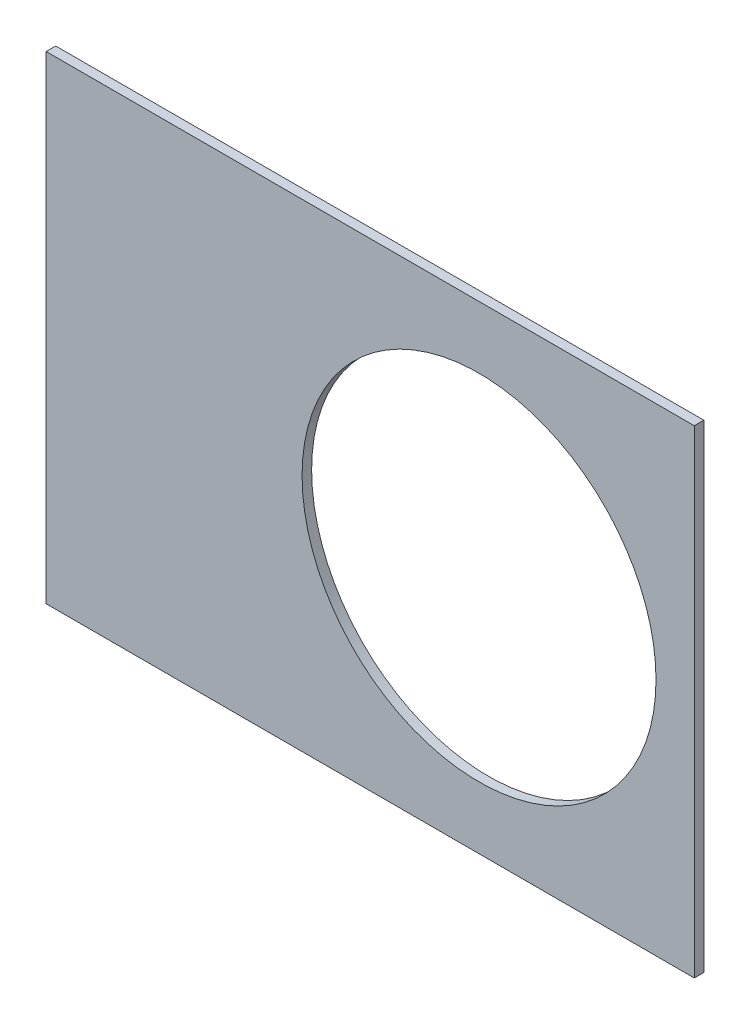
from build123d import *

# Parameters (mm, degrees)
BOSS_EXTRUDE1_DEPTH = 0.254
SKETCH2_R           = 4.699
CUT_EXTRUDE1_DEPTH  = 1.254
SKETCH3_W           = 2.54
SKETCH3_H           = 0.635
CUT_EXTRUDE2_DEPTH  = 1.254
SKETCH5_OUTSIDE_W   = 121.447
SKETCH5_OUTSIDE_H   = 109.618
SKETCH5_OUTSIDE_W_2 = 17.2085
SKETCH5_OUTSIDE_H_2 = 15.24
CUT_EXTRUDE5_DEPTH  = 1.254


with BuildPart() as part:
    # Sketch1 → Boss-Extrude1 (new body)
    with BuildSketch(Plane.XY):
        with BuildLine():
            Line((67.21146711, 76.191723231), (8.696654013, 17.676910134))
            Line((8.696654013, 17.676910134), (7.228954972, 14.133571205))
            ThreePointArc((7.228954972, 14.133571205), (14.666587579, 6.075099489), (15.105587123, -4.88230096))
            Line((15.105587123, -4.88230096), (18.648926052, -6.35))
            Line((18.648926052, -6.35), (101.401368334, -6.35))
            ThreePointArc((101.401368334, -6.35), (93.866160503, 38.880636728), (67.21146711, 76.191723231))
        make_face()
        with BuildLine():
            Line((88.672924278, 6.35), (27.86051193, 6.35))
            ThreePointArc((27.86051193, 6.35), (26.399857642, 10.93517908), (24.190484974, 15.210228852))
            Line((24.190484974, 15.210228852), (67.191354125, 58.211098004))
            ThreePointArc((67.191354125, 58.211098004), (82.13289044, 34.020557137), (88.672924278, 6.35))
        make_face(mode=Mode.SUBTRACT)
    extrude(amount=BOSS_EXTRUDE1_DEPTH)

    # Sketch2 → Cut-Extrude1 (cut, through all)
    with BuildSketch(Plane.XY.offset(0.254)):
        with Locations((22.225, 0)):
            Circle(SKETCH2_R)
        with Locations((36.195, 0)):
            Circle(SKETCH2_R)
        with Locations((61.722, 0)):
            Circle(SKETCH2_R)
        with Locations((75.692, 0)):
            Circle(SKETCH2_R)
        with Locations((95.25, 0)):
            Circle(SKETCH2_R)
        with Locations((15.715448212, 15.715448212)):
            Circle(SKETCH2_R)
        with Locations((25.593729945, 25.593729945)):
            Circle(SKETCH2_R)
        with Locations((43.644044748, 43.644044748)):
            Circle(SKETCH2_R)
        with Locations((53.522326482, 53.522326482)):
            Circle(SKETCH2_R)
        with Locations((92.004434954, 24.652514046)):
            Circle(SKETCH2_R)
        with Locations((82.48891971, 47.625)):
            Circle(SKETCH2_R)
        with Locations((67.351920908, 67.351920908)):
            Circle(SKETCH2_R)
    extrude(amount=-CUT_EXTRUDE1_DEPTH, mode=Mode.SUBTRACT)

    # Sketch3 → Cut-Extrude2 (cut, through all)
    with BuildSketch(Plane.XY.offset(0.254)):
        Polygon((15.266435406, 24.246691527), (17.06248663, 26.042742751), (17.511499436, 25.593729945), (15.715448212, 23.797678721), align=None)
        Polygon((44.991083167, 53.971339288), (43.195031942, 52.175288063), (43.644044748, 51.726275257), (45.440095973, 53.522326482), align=None)
        with Locations((29.21, -6.0325)):
            Rectangle(SKETCH3_W, SKETCH3_H)
        with Locations((68.707, -6.0325)):
            Rectangle(SKETCH3_W, SKETCH3_H)
        Polygon((29.230733674, 38.210989795), (31.026784898, 40.007041019), (31.475797704, 39.558028213), (29.67974648, 37.761976989), align=None)
        Polygon((56.845021246, 65.825277367), (55.048970022, 64.029226143), (55.497982828, 63.580213337), (57.294034052, 65.376264561), align=None)
        with Locations((48.9585, -6.0325)):
            Rectangle(SKETCH3_W, SKETCH3_H)
        with Locations((85.471, -6.0325)):
            Rectangle(SKETCH3_W, SKETCH3_H)
        Polygon((99.935462164, 14.437711971), (100.266998693, 11.919442024), (101.526133667, 12.085210288), (101.194597138, 14.603480236), align=None)
        Polygon((93.765504959, 37.464305742), (94.938831965, 37.950313702), (93.966816047, 40.296967714), (92.793489041, 39.810959755), align=None)
        Polygon((79.327792988, 62.471156422), (80.874047017, 60.456038938), (81.88160576, 61.229165953), (80.33535173, 63.244283437), align=None)
        Polygon((13.593916116, 7.005422516), (14.565932035, 4.658768503), (15.739259041, 5.144776462), (14.767243123, 7.491430475), align=None)
    extrude(amount=-CUT_EXTRUDE2_DEPTH, mode=Mode.SUBTRACT)

    # Sketch5 outside → Cut-Extrude5 (cut, through all)
    with BuildSketch(Plane.XY.offset(0.254)):
        with Locations((54.4145, 34.921)):
            Rectangle(SKETCH5_OUTSIDE_W, SKETCH5_OUTSIDE_H)
        with Locations((58.83275, 0)):
            Rectangle(SKETCH5_OUTSIDE_W_2, SKETCH5_OUTSIDE_H_2, mode=Mode.SUBTRACT)
    extrude(amount=-CUT_EXTRUDE5_DEPTH, mode=Mode.SUBTRACT)


solid = part.part
